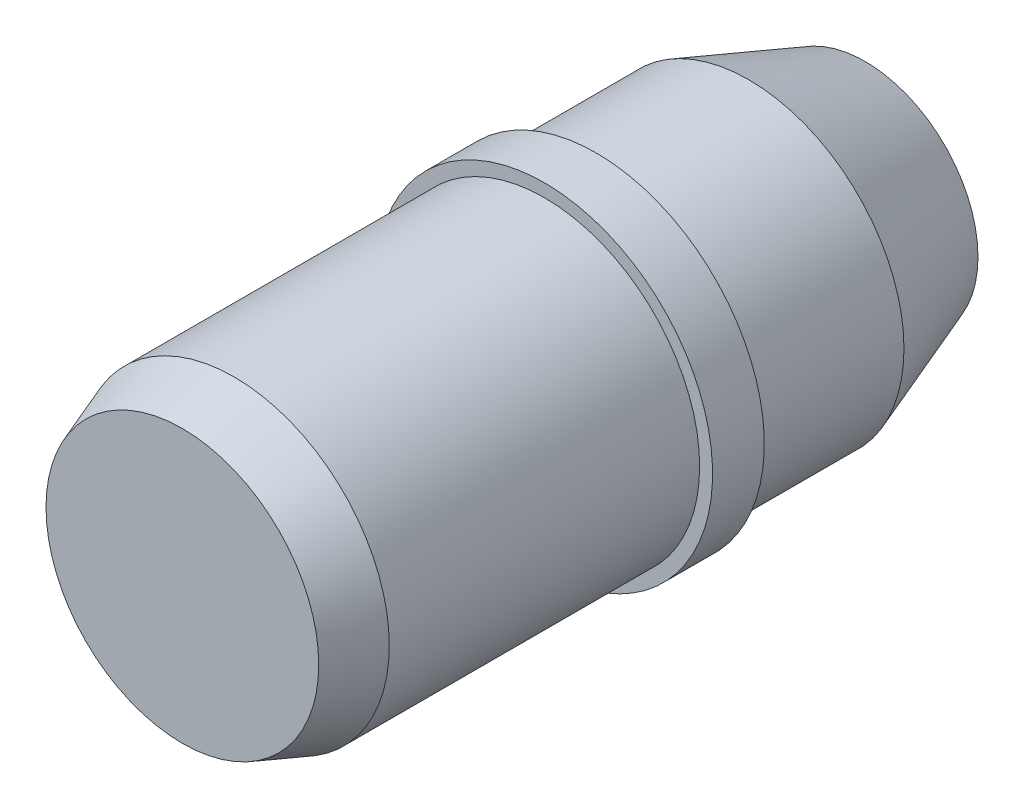
from build123d import *

# Parameters (mm, degrees)
SKETCH1_R           = 3
BOSS_EXTRUDE1_DEPTH = 7
CHAMFER1_SIZE       = 1
CHAMFER1_SIZE2      = 0.363970234
SKETCH2_R           = 3.25
BOSS_EXTRUDE3_DEPTH = 1
BOSS_EXTRUDE4_START = 5.2
SKETCH4_R           = 3
BOSS_EXTRUDE4_DEPTH = 5.2
CHAMFER2_SIZE       = 2.25
CHAMFER2_SIZE2      = 0.818933027
SKETCH2_2_R         = 3.25
BOSS_EXTRUDE5_DEPTH = 1


with BuildPart() as part:
    # Sketch1 → Boss-Extrude1 (new body)
    with BuildSketch(Plane.XY):
        Circle(SKETCH1_R)
    extrude(amount=BOSS_EXTRUDE1_DEPTH)

    # Chamfer1
    chamfer1_edges = [part.edges().sort_by_distance(p)[0] for p in [
        (-3, 0, 7),
    ]]
    chamfer1_side = [part.faces().sort_by_distance(p)[0] for p in [
        (-3, 0, 3.5),
    ]]
    chamfer(chamfer1_edges, length=CHAMFER1_SIZE, length2=CHAMFER1_SIZE2, reference=chamfer1_side[0])

    # Sketch2 → Boss-Extrude3 (add)
    with BuildSketch(Plane(origin=(0, 0, 0), x_dir=(-1, 0, 0), z_dir=(0, 0, -1))):
        Circle(SKETCH2_R)
    extrude(amount=BOSS_EXTRUDE3_DEPTH)

    # Sketch4 → Boss-Extrude4 (add)
    with BuildSketch(Plane(origin=(0, 0, -1), x_dir=(-1, 0, 0), z_dir=(0, 0, -1)).offset(BOSS_EXTRUDE4_START)):
        Circle(SKETCH4_R)
    extrude(amount=-BOSS_EXTRUDE4_DEPTH)

    # Chamfer2
    chamfer2_edges = [part.edges().sort_by_distance(p)[0] for p in [
        (3, 0, -6.2),
    ]]
    chamfer2_side = [part.faces().sort_by_distance(p)[0] for p in [
        (3, 0, -3.6),
    ]]
    chamfer(chamfer2_edges, length=CHAMFER2_SIZE, length2=CHAMFER2_SIZE2, reference=chamfer2_side[0])

    # Sketch2_2 → Boss-Extrude5 (add)
    with BuildSketch(Plane(origin=(0, 0, 0), x_dir=(-1, 0, 0), z_dir=(0, 0, -1))):
        Circle(SKETCH2_2_R)
    extrude(amount=BOSS_EXTRUDE5_DEPTH)


solid = part.part
